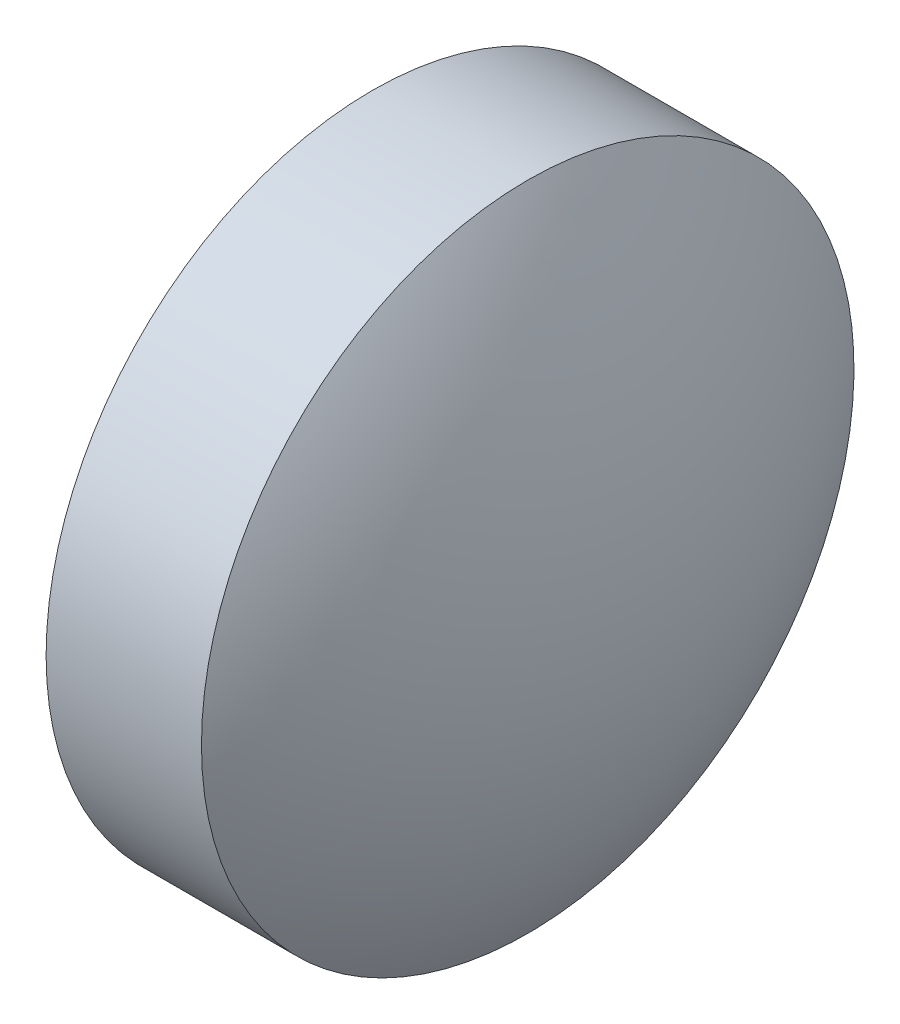
from build123d import *

# Parameters (mm, degrees)
SKETCH_2_ONE_SIDE_W = 1.5
SKETCH_2_ONE_SIDE_H = 3.1500126


with BuildPart() as part:
    # 草图2 one side → 旋转1 (revolve)
    with BuildSketch(Plane.XY):
        with Locations((21.444440927, 13.633381779)):
            Rectangle(SKETCH_2_ONE_SIDE_W, SKETCH_2_ONE_SIDE_H)
        with BuildLine():
            Line((19.775723052, 12.058375479), (20.694440927, 12.058375479))
            Line((20.694440927, 12.058375479), (20.694440927, 15.208388079))
            ThreePointArc((20.694440927, 15.208388079), (20.010089506, 13.69900203), (19.775723052, 12.058375479))
        make_face()
        with BuildLine():
            Line((22.194440927, 12.058375479), (23.113158802, 12.058375479))
            ThreePointArc((23.113158802, 12.058375479), (22.878792347, 13.69900203), (22.194440927, 15.208388079))
            Line((22.194440927, 15.208388079), (22.194440927, 12.058375479))
        make_face()
    revolve(axis=Axis((18.264768098, 12.058375479, 0), (1, 0, 0)))


solid = part.part
